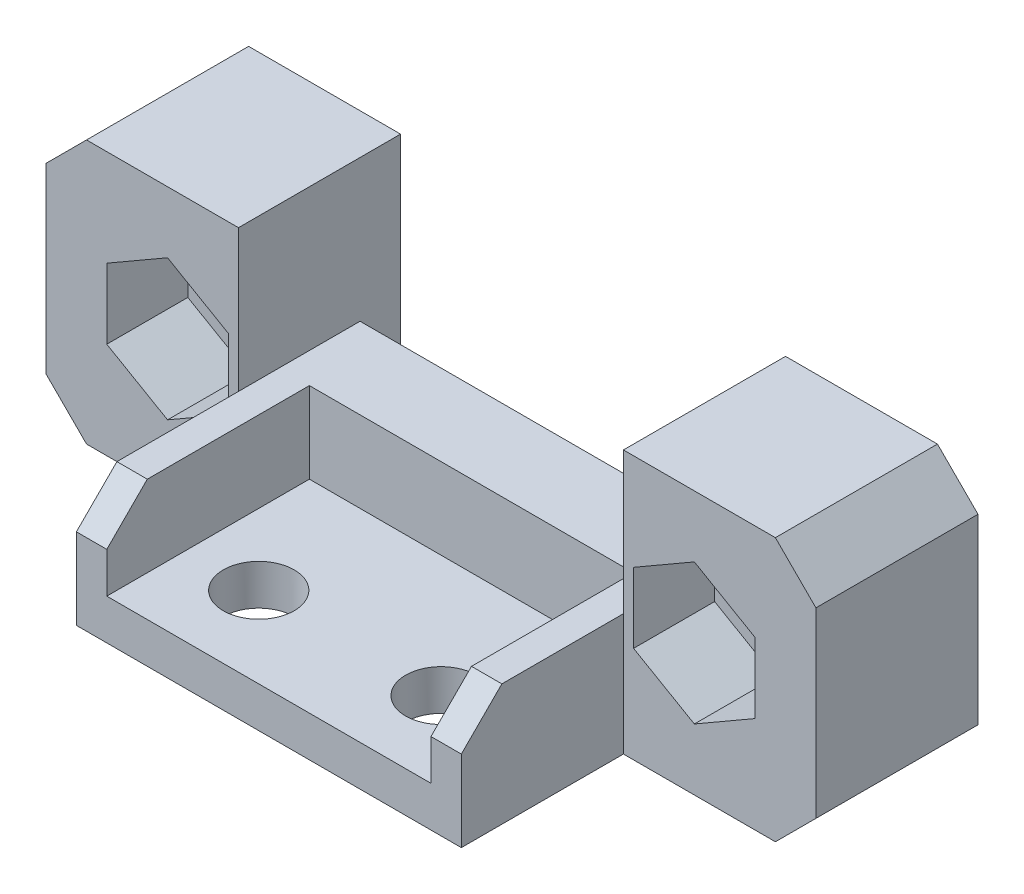
from build123d import *

# Parameters (mm, degrees)
SKETCH1_W           = 38
SKETCH1_H           = 13
BOSS_EXTRUDE1_DEPTH = 8
SKETCH2_W           = 19
SKETCH2_H           = 14
CUT_EXTRUDE1_DEPTH  = 9
SKETCH3_R           = 2
CUT_EXTRUDE2_DEPTH  = 9
SKETCH4_W           = 19
SKETCH4_H           = 6
BOSS_EXTRUDE2_DEPTH = 8
SKETCH5_R           = 1.75
CUT_EXTRUDE3_DEPTH  = 7
CUT_EXTRUDE4_DEPTH  = 4
SKETCH7_W           = 16
SKETCH7_H           = 10
CUT_EXTRUDE5_DEPTH  = 4
CHAMFER1_SIZE       = 2
SKETCH8_W           = 19
SKETCH8_H           = 2
CUT_EXTRUDE6_DEPTH  = 7


with BuildPart() as part:
    # Sketch1 → Boss-Extrude1 (new body)
    with BuildSketch(Plane.XY):
        Rectangle(SKETCH1_W, SKETCH1_H)
    extrude(amount=BOSS_EXTRUDE1_DEPTH)

    # Sketch2 → Cut-Extrude1 (cut, through all)
    with BuildSketch(Plane.XY.offset(8)):
        with Locations((0, 6.5)):
            Rectangle(SKETCH2_W, SKETCH2_H)
    extrude(amount=-CUT_EXTRUDE1_DEPTH, mode=Mode.SUBTRACT)

    # Sketch3 → Cut-Extrude2 (cut, through all)
    with BuildSketch(Plane.XY.offset(8)):
        with Locations((-13, 0)):
            Circle(SKETCH3_R)
        with Locations((13, 0)):
            Circle(SKETCH3_R)
    extrude(amount=-CUT_EXTRUDE2_DEPTH, mode=Mode.SUBTRACT)

    # Sketch4 → Boss-Extrude2 (add)
    with BuildSketch(Plane.XY.offset(8)):
        with Locations((0, -3.5)):
            Rectangle(SKETCH4_W, SKETCH4_H)
    extrude(amount=BOSS_EXTRUDE2_DEPTH)

    # Sketch5 → Cut-Extrude3 (cut, through all)
    with BuildSketch(Plane(origin=(0, -0.5, 0), x_dir=(1, 0, 0), z_dir=(0, 1, 0))):
        with Locations((-4.5, -12)):
            Circle(SKETCH5_R)
        with Locations((4.5, -12)):
            Circle(SKETCH5_R)
    extrude(amount=-CUT_EXTRUDE3_DEPTH, mode=Mode.SUBTRACT)

    # Sketch6 → Cut-Extrude4 (cut)
    with BuildSketch(Plane.XY.offset(8)):
        Polygon((-13, 3.464101615), (-16, 1.732050808), (-16, -1.732050808), (-13, -3.464101615), (-10, -1.732050808), (-10, 1.732050808), align=None)
        Polygon((13, -3.464101615), (16, -1.732050808), (16, 1.732050808), (13, 3.464101615), (10, 1.732050808), (10, -1.732050808), align=None)
    extrude(amount=-CUT_EXTRUDE4_DEPTH, mode=Mode.SUBTRACT)

    # Sketch7 → Cut-Extrude5 (cut)
    with BuildSketch(Plane(origin=(0, -0.5, 0), x_dir=(1, 0, 0), z_dir=(0, 1, 0))):
        with Locations((0, -11)):
            Rectangle(SKETCH7_W, SKETCH7_H)
    extrude(amount=-CUT_EXTRUDE5_DEPTH, mode=Mode.SUBTRACT)

    # Chamfer1
    chamfer1_edges = [part.edges().sort_by_distance(p)[0] for p in [
        (-8.75, -0.5, 16),
        (8.75, -0.5, 16),
        (19, -6.5, 4),
        (-19, -6.5, 4),
        (-19, 6.5, 4),
        (19, 6.5, 4),
    ]]
    chamfer(chamfer1_edges, length=CHAMFER1_SIZE)

    # Sketch8 → Cut-Extrude6 (cut, through all)
    with BuildSketch(Plane(origin=(0, -0.5, 0), x_dir=(1, 0, 0), z_dir=(0, 1, 0))):
        with Locations((0, -1)):
            Rectangle(SKETCH8_W, SKETCH8_H)
    extrude(amount=-CUT_EXTRUDE6_DEPTH, mode=Mode.SUBTRACT)


solid = part.part
